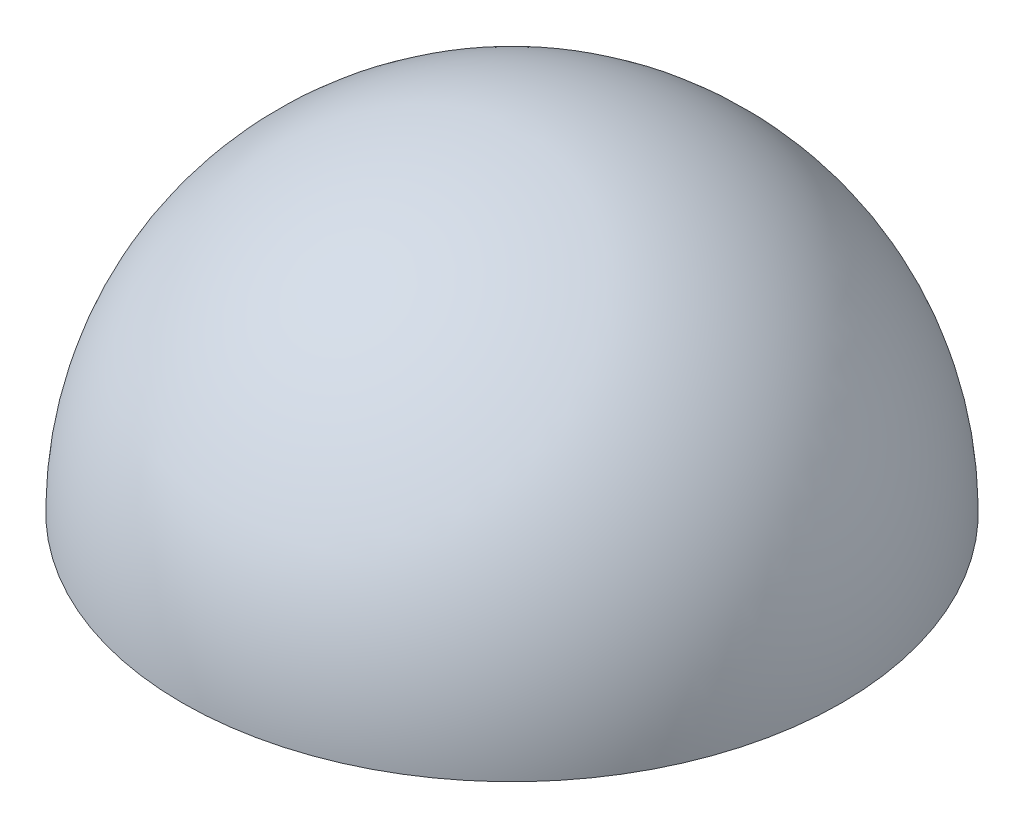
from build123d import *


with BuildPart() as part:
    # Sketch3 → Revolve1 (revolve)
    with BuildSketch(Plane(origin=(0, 0, 0), x_dir=(0, 0, -1), z_dir=(1, 0, 0))):
        with BuildLine():
            Line((263.352848866, -179.932349801), (263.352848866, -206.142744187))
            Line((263.352848866, -206.142744187), (289.563243252, -206.142744187))
            ThreePointArc((289.563243252, -206.142744187), (281.886396474, -187.609196579), (263.352848866, -179.932349801))
        make_face()
    revolve(axis=Axis((0, -179.932349801, -263.352848866), (0, -1, 0)))


solid = part.part
